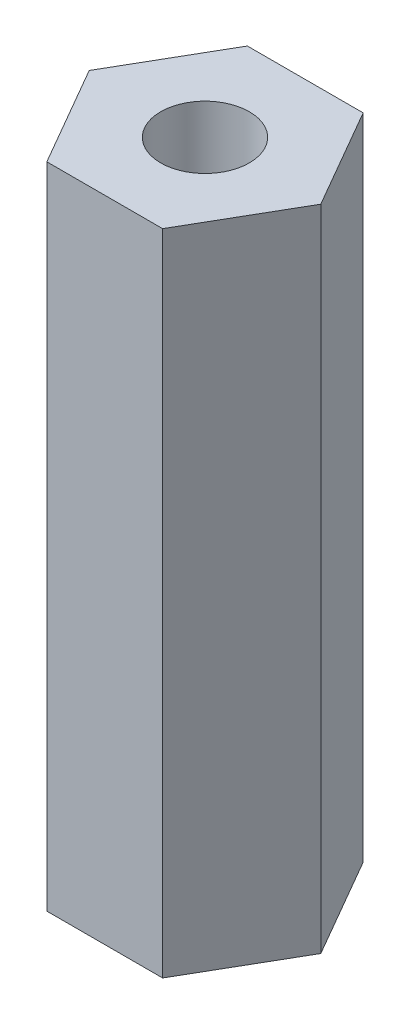
from build123d import *

# Parameters (mm, degrees)
BOSS_EXTRUDE1_DEPTH          = 15
M2_5X0_45_TAPPED_HOLE1_D     = 2.05
M2_5X0_45_TAPPED_HOLE1_DEPTH = 42
M2_5X0_45_TAPPED_HOLE1_TIP   = 0.615882135


with BuildPart() as part:
    # Sketch1 → Boss-Extrude1 (new body)
    with BuildSketch(Plane(origin=(0, 0, 0), x_dir=(1, 0, 0), z_dir=(0, 1, 0))):
        Polygon((1.338153586, -2.31775), (2.676307173, 0), (1.338153586, 2.31775), (-1.338153586, 2.31775), (-2.676307173, 0), (-1.338153586, -2.31775), align=None)
    extrude(amount=BOSS_EXTRUDE1_DEPTH)

    # M2.5x0.45 Tapped Hole1
    with Locations(Plane(origin=(0, 0, 0), x_dir=(-1, 0, 0), z_dir=(0, -1, 0))):
        with Locations((0, 0)):
            Hole(M2_5X0_45_TAPPED_HOLE1_D / 2, depth=M2_5X0_45_TAPPED_HOLE1_DEPTH)
            with Locations((0, 0, -(M2_5X0_45_TAPPED_HOLE1_DEPTH + M2_5X0_45_TAPPED_HOLE1_TIP / 2))):  # 118° drill point
                Cone(0, M2_5X0_45_TAPPED_HOLE1_D / 2, M2_5X0_45_TAPPED_HOLE1_TIP, mode=Mode.SUBTRACT)


solid = part.part
